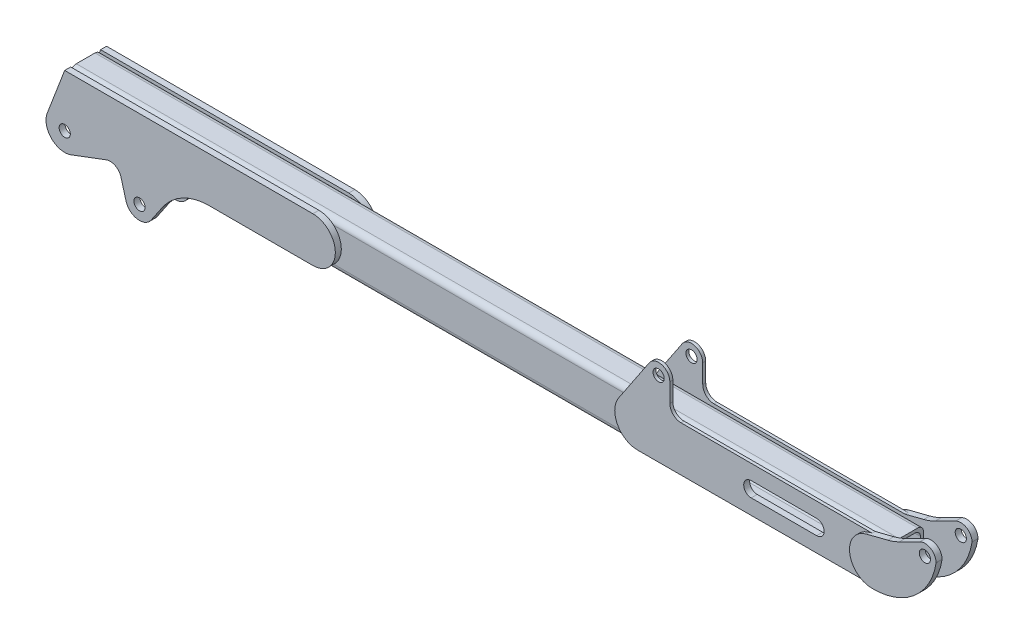
from build123d import *

# Parameters (mm, degrees)
SKETCH2_W               = 80
SKETCH2_H               = 120
SKETCH2_W_2             = 64
SKETCH2_H_2             = 104
BOSS_EXTRUDE1_DEPTH     = 2200
FILLET4_R               = 15
SKETCH4_R               = 15
BOSS_EXTRUDE2_DEPTH     = 16
FILLET1_R               = 30
FILLET2_R               = 150
FILLET1_OF_MIRROR1_R    = 30
FILLET2_OF_MIRROR1_R    = 150
SKETCH5_R               = 15
BOSS_EXTRUDE3_DEPTH     = 16
FILLET3_R               = 150
SKETCH9_R               = 15
BOSS_EXTRUDE4_DEPTH     = 8
FILLET5_R               = 30
FILLET3_OF_MIRROR5_R    = 150
FILLET5_OF_MIRROR5_R    = 30
CUT_EXTRUDE1_DEPTH      = 17
CUT_EXTRUDE1_DEPTH_BACK = 97


with BuildPart() as part:
    # Sketch2 → Boss-Extrude1 (new body)
    with BuildSketch(Plane(origin=(0, 0, 0), x_dir=(0, 0, -1), z_dir=(1, 0, 0))):
        with Locations((0, 80)):
            Rectangle(SKETCH2_W, SKETCH2_H)
        with Locations((0, 80)):
            Rectangle(SKETCH2_W_2, SKETCH2_H_2, mode=Mode.SUBTRACT)
    extrude(amount=BOSS_EXTRUDE1_DEPTH)

    # Fillet4
    fillet4_edges = [part.edges().sort_by_distance(p)[0] for p in [
        (1100, 132, 32),
        (1100, 28, 32),
        (1100, 28, -32),
        (1100, 132, -32),
        (1100, 20, -40),
        (1100, 20, 40),
        (1100, 140, 40),
        (1100, 140, -40),
    ]]
    fillet(fillet4_edges, radius=FILLET4_R)

    # Sketch4 → Boss-Extrude2 (add)
    with BuildSketch(Plane.XY.offset(40)):
        with BuildLine():
            Line((663.616754147, 140), (0, 140))
            Line((0, 140), (-46.702488681, 17.857142857))
            ThreePointArc((-46.702488681, 17.857142857), (-35.438939598, -35.271540371), (17.635818001, -46.786514333))
            Line((17.635818001, -46.786514333), (141.756963012, 0))
            Line((141.756963012, 0), (163.853984354, -79.985767518))
            ThreePointArc((163.853984354, -79.985767518), (193.903117134, -107.0010543), (231.031250542, -91.054963543))
            Line((231.031250542, -91.054963543), (306.382973978, 20))
            Line((306.382973978, 20), (663.616754147, 20))
            ThreePointArc((663.616754147, 20), (723.616754147, 80), (663.616754147, 140))
        make_face()
        Circle(SKETCH4_R, mode=Mode.SUBTRACT)
        with Locations((200, -70)):
            Circle(SKETCH4_R, mode=Mode.SUBTRACT)
    boss_extrude2 = extrude(amount=BOSS_EXTRUDE2_DEPTH)

    # Fillet1
    fillet1_edges = [part.edges().sort_by_distance(p)[0] for p in [
        (141.756963012, 0, 48),
    ]]
    fillet(fillet1_edges, radius=FILLET1_R)

    # Fillet2
    fillet2_edges = [part.edges().sort_by_distance(p)[0] for p in [
        (306.382973978, 20, 48),
    ]]
    fillet(fillet2_edges, radius=FILLET2_R)

    # Mirror1: Boss-Extrude2 across plane
    add(boss_extrude2.mirror(Plane(origin=(0, 0, 0), x_dir=(1, 0, 0), z_dir=(0, 0, -1))))

    # Fillet1 of Mirror1
    fillet1_of_mirror1_edges = [part.edges().sort_by_distance(p)[0] for p in [
        (141.756963012, 0, -48),
    ]]
    fillet(fillet1_of_mirror1_edges, radius=FILLET1_OF_MIRROR1_R)

    # Fillet2 of Mirror1
    fillet2_of_mirror1_edges = [part.edges().sort_by_distance(p)[0] for p in [
        (306.382973978, 20, -48),
    ]]
    fillet(fillet2_of_mirror1_edges, radius=FILLET2_OF_MIRROR1_R)



with BuildPart() as body_2:
    # Sketch5 → Boss-Extrude3 (new body)
    with BuildSketch(Plane.XY.offset(40)):
        with BuildLine():
            ThreePointArc((2156.472909481, 20.031536396), (2270.867590896, 59.441328796), (2330, 165))
            ThreePointArc((2330, 165), (2315.741185035, 190.538502182), (2286.518993754, 191.800419224))
            Line((2286.518993754, 191.800419224), (2216.86153125, 156.761687956))
            Line((2216.86153125, 156.761687956), (2143.638230406, 138.15116888))
            ThreePointArc((2143.638230406, 138.15116888), (2098.769091881, 73.518650853), (2156.472909481, 20.031536396))
        make_face()
        with Locations((2300, 165)):
            Circle(SKETCH5_R, mode=Mode.SUBTRACT)
    boss_extrude3 = extrude(amount=BOSS_EXTRUDE3_DEPTH)

    # Fillet3
    fillet3_edges = [body_2.edges().sort_by_distance(p)[0] for p in [
        (2216.86153125, 156.761687956, 48),
    ]]
    fillet(fillet3_edges, radius=FILLET3_R)


with BuildPart() as part_1:
    add(part.part)

    add(body_2.part)  # Boss-Extrude4 merges body 2
    # Sketch9 → Boss-Extrude4 (add)
    with BuildSketch(Plane.XY.offset(40)):
        with BuildLine():
            Line((1610, 140), (2157.550798688, 140))
            Line((2157.550798688, 140), (2157.550798688, 20))
            Line((2157.550798688, 20), (1524.006966774, 18.707022476))
            ThreePointArc((1524.006966774, 18.707022476), (1469.944566534, 51.119453365), (1473.059803349, 114.07661416))
            Line((1473.059803349, 114.07661416), (1555.063784392, 236.678883391))
            ThreePointArc((1555.063784392, 236.678883391), (1588.715317888, 248.706153245), (1610, 220))
            Line((1610, 220), (1610, 140))
        make_face()
        with Locations((1580, 220)):
            Circle(SKETCH9_R, mode=Mode.SUBTRACT)
    boss_extrude4 = extrude(amount=BOSS_EXTRUDE4_DEPTH)

    # Fillet5
    fillet5_edges = [part_1.edges().sort_by_distance(p)[0] for p in [
        (1610, 140, 44),
    ]]
    fillet(fillet5_edges, radius=FILLET5_R)

    # Mirror5: Boss-Extrude3, Boss-Extrude4 across plane
    add(boss_extrude3.mirror(Plane(origin=(0, 0, 0), x_dir=(1, 0, 0), z_dir=(0, 0, -1))))
    add(boss_extrude4.mirror(Plane(origin=(0, 0, 0), x_dir=(1, 0, 0), z_dir=(0, 0, -1))))

    # Fillet3 of Mirror5
    fillet3_of_mirror5_edges = [part_1.edges().sort_by_distance(p)[0] for p in [
        (2216.86153125, 156.761687956, -48),
    ]]
    fillet(fillet3_of_mirror5_edges, radius=FILLET3_OF_MIRROR5_R)

    # Fillet5 of Mirror5
    fillet5_of_mirror5_edges = [part_1.edges().sort_by_distance(p)[0] for p in [
        (1610, 140, -44),
    ]]
    fillet(fillet5_of_mirror5_edges, radius=FILLET5_OF_MIRROR5_R)

    # Sketch6 → Cut-Extrude1 (cut, two sides)
    with BuildSketch(Plane.XY.offset(40)) as cut_extrude1_sk:
        with BuildLine():
            Line((1827.553025368, 100), (2002.553025368, 100))
            ThreePointArc((2002.553025368, 100), (2022.553025368, 80), (2002.553025368, 60))
            Line((2002.553025368, 60), (1827.553025368, 60))
            ThreePointArc((1827.553025368, 60), (1807.553025368, 80), (1827.553025368, 100))
        make_face()
    extrude(amount=CUT_EXTRUDE1_DEPTH, mode=Mode.SUBTRACT)
    extrude(cut_extrude1_sk.sketch, amount=-CUT_EXTRUDE1_DEPTH_BACK, mode=Mode.SUBTRACT)


solid = part_1.part
